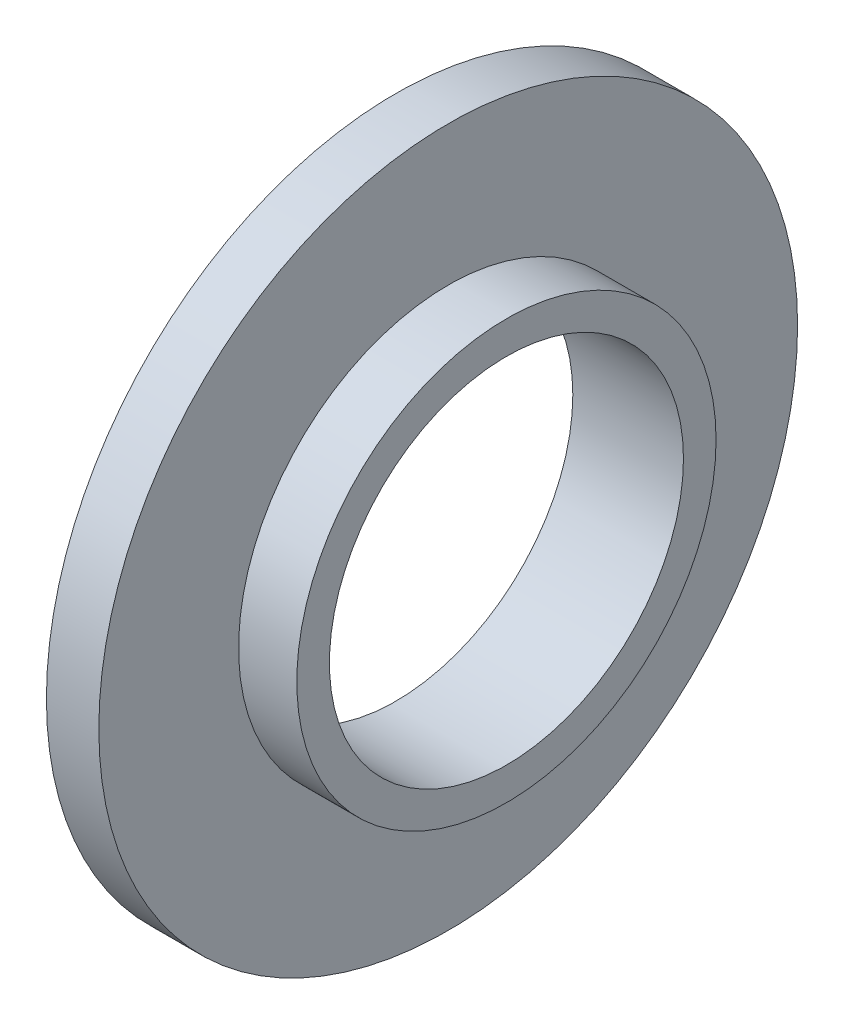
from build123d import *

# Parameters (mm, degrees)
SKETCH_1_R          = 30
EXTRUDE_1_DEPTH     = 4.5
SKETCH_2_R          = 18
EXTRUDE_2_DEPTH     = 5
SKETCH_3_R          = 15.2
CUT_EXTRUDE_1_DEPTH = 10.5


with BuildPart() as part:
    # 草图1 → 凸台-拉伸1 (new body)
    with BuildSketch(Plane(origin=(0, 0, 0), x_dir=(0, 0, -1), z_dir=(1, 0, 0))):
        Circle(SKETCH_1_R)
    extrude(amount=EXTRUDE_1_DEPTH)

    # 草图2 → 凸台-拉伸2 (add)
    with BuildSketch(Plane(origin=(4.5, 0, 0), x_dir=(0, 0, -1), z_dir=(1, 0, 0))):
        Circle(SKETCH_2_R)
    extrude(amount=EXTRUDE_2_DEPTH)

    # 草图3 → 切除-拉伸1 (cut, through all)
    with BuildSketch(Plane(origin=(9.5, 0, 0), x_dir=(0, 0, -1), z_dir=(1, 0, 0))):
        Circle(SKETCH_3_R)
    extrude(amount=-CUT_EXTRUDE_1_DEPTH, mode=Mode.SUBTRACT)


solid = part.part
